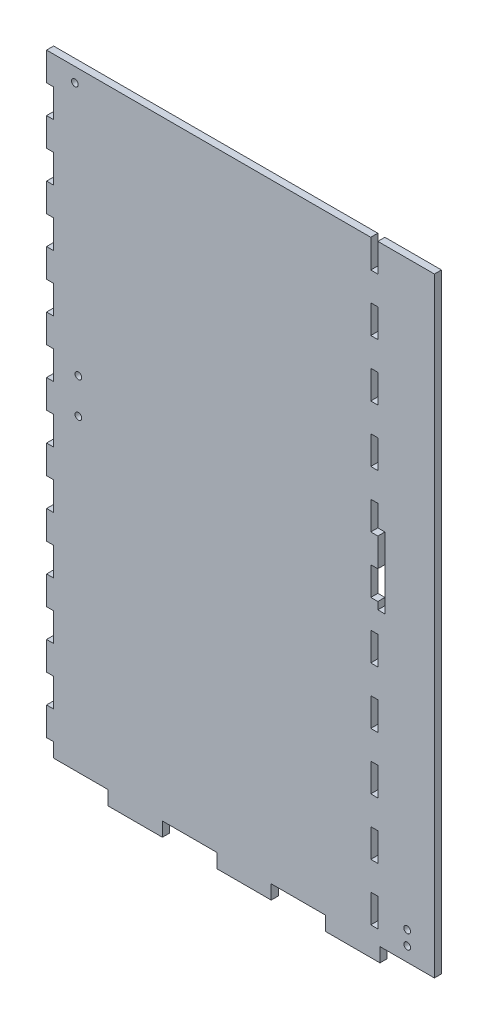
from build123d import *

# Parameters (mm, degrees)
SKETCH1_W           = 3.175
SKETCH1_H           = 12.734636364
SKETCH1_H_2         = 12.734636363
BOSS_EXTRUDE1_DEPTH = 3.175
SKETCH2_R           = 1.5
SKETCH2_W           = 3.175
SKETCH2_H           = 31.877
CUT_EXTRUDE1_DEPTH  = 4.175


with BuildPart() as part:
    # Sketch1 → Boss-Extrude1 (new body)
    with BuildSketch(Plane.XY):
        Polygon((24.429357143, -133.731), (24.429357143, -140.081), (48.858714286, -140.081), (48.858714286, -133.731), (73.288071429, -133.731), (73.288071429, -140.081), (97.717428571, -140.081), (97.717428571, -133.731), (122.146785714, -133.731), (122.146785714, -140.081), (146.576142857, -140.081), (146.576142857, -133.731), (171.0055, -133.731), (171.0055, 140.081), (145.6055, 140.081), (145.6055, 127.346363636), (142.4305, 127.346363636), (142.4305, 140.081), (-3.175, 140.081), (-3.175, 127.346363636), (0, 127.346363636), (0, 114.611727273), (-3.175, 114.611727273), (-3.175, 101.877090909), (0, 101.877090909), (0, 89.142454545), (-3.175, 89.142454545), (-3.175, 76.407818182), (0, 76.407818182), (0, 63.673181818), (-3.175, 63.673181818), (-3.175, 50.938545455), (0, 50.938545455), (0, 38.203909091), (-3.175, 38.203909091), (-3.175, 25.469272727), (0, 25.469272727), (0, 12.734636364), (-3.175, 12.734636364), (-3.175, 0), (0, 0), (0, -12.734636364), (-3.175, -12.734636364), (-3.175, -25.469272727), (0, -25.469272727), (0, -38.203909091), (-3.175, -38.203909091), (-3.175, -50.938545455), (0, -50.938545455), (0, -63.673181818), (-3.175, -63.673181818), (-3.175, -76.407818182), (0, -76.407818182), (0, -89.142454545), (-3.175, -89.142454545), (-3.175, -101.877090909), (0, -101.877090909), (0, -114.611727273), (-3.175, -114.611727273), (-3.175, -127.346363636), (0, -127.346363636), (0, -133.731), align=None)
        with Locations((144.018, 108.244409091)):
            Rectangle(SKETCH1_W, SKETCH1_H, mode=Mode.SUBTRACT)
        with Locations((144.018, -120.979045455)):
            Rectangle(SKETCH1_W, SKETCH1_H_2, mode=Mode.SUBTRACT)
        with Locations((144.018, -95.509772727)):
            Rectangle(SKETCH1_W, SKETCH1_H, mode=Mode.SUBTRACT)
        with Locations((144.018, -70.0405)):
            Rectangle(SKETCH1_W, SKETCH1_H, mode=Mode.SUBTRACT)
        with Locations((144.018, -44.571227273)):
            Rectangle(SKETCH1_W, SKETCH1_H, mode=Mode.SUBTRACT)
        with Locations((144.018, -19.101954545)):
            Rectangle(SKETCH1_W, SKETCH1_H_2, mode=Mode.SUBTRACT)
        with Locations((144.018, 6.367318182)):
            Rectangle(SKETCH1_W, SKETCH1_H, mode=Mode.SUBTRACT)
        with Locations((144.018, 31.836590909)):
            Rectangle(SKETCH1_W, SKETCH1_H, mode=Mode.SUBTRACT)
        with Locations((144.018, 57.305863637)):
            Rectangle(SKETCH1_W, SKETCH1_H_2, mode=Mode.SUBTRACT)
        with Locations((144.018, 82.775136363)):
            Rectangle(SKETCH1_W, SKETCH1_H_2, mode=Mode.SUBTRACT)
    extrude(amount=BOSS_EXTRUDE1_DEPTH)

    # Sketch2 → Cut-Extrude1 (cut, through all)
    with BuildSketch(Plane.XY.offset(3.175)):
        with Locations((158.790821429, -121.031)):
            Circle(SKETCH2_R)
        with Locations((11.1125, 20.574)):
            Circle(SKETCH2_R)
        with Locations((11.1125, 4.826)):
            Circle(SKETCH2_R)
        with Locations((158.790821429, -127.381)):
            Circle(SKETCH2_R)
        with Locations((9.525, 133.731)):
            Circle(SKETCH2_R)
        with Locations((147.193, 12.7)):
            Rectangle(SKETCH2_W, SKETCH2_H)
    extrude(amount=-CUT_EXTRUDE1_DEPTH, mode=Mode.SUBTRACT)


solid = part.part
